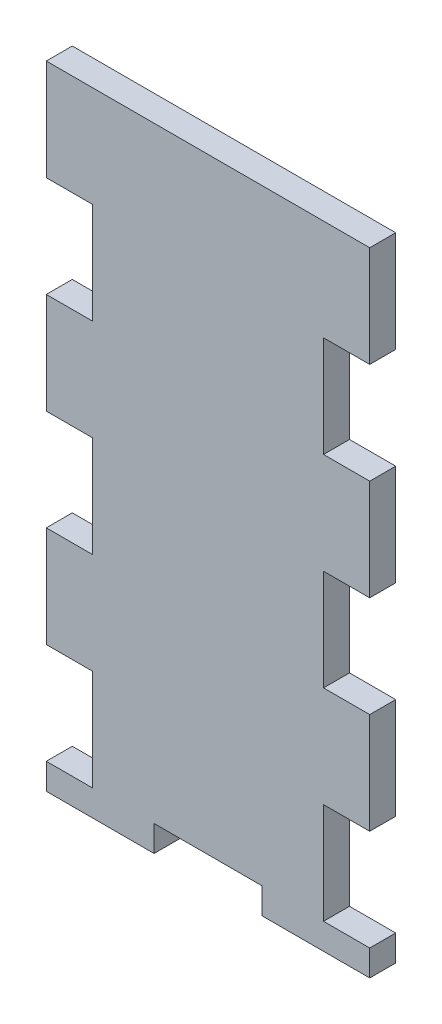
from build123d import *

# Parameters (mm, degrees)
SKETCH1_W           = 20
SKETCH1_H           = 70
SKETCH1_W_2         = 4
SKETCH1_H_2         = 8.75
BOSS_EXTRUDE1_DEPTH = 2.25
SKETCH2_W           = 28
SKETCH2_H           = 2.25
BOSS_EXTRUDE2_DEPTH = 2.25
SKETCH3_W           = 9.333333334
SKETCH3_H           = 2.25
CUT_EXTRUDE1_DEPTH  = 3.25
SKETCH4_W           = 2.25
SKETCH4_H           = 8.75
CUT_EXTRUDE2_DEPTH  = 3.25
SKETCH5_W           = 28
SKETCH5_H           = 17.5
CUT_EXTRUDE3_DEPTH  = 3.25


with BuildPart() as part:
    # Sketch1 → Boss-Extrude1 (new body)
    with BuildSketch(Plane.XY):
        with Locations((10, 35)):
            Rectangle(SKETCH1_W, SKETCH1_H)
        with Locations((-2, 48.125)):
            Rectangle(SKETCH1_W_2, SKETCH1_H_2)
        with Locations((-2, 13.125)):
            Rectangle(SKETCH1_W_2, SKETCH1_H_2)
        with Locations((-2, 65.625)):
            Rectangle(SKETCH1_W_2, SKETCH1_H_2)
        with Locations((22, 65.625)):
            Rectangle(SKETCH1_W_2, SKETCH1_H_2)
        with Locations((22, 48.125)):
            Rectangle(SKETCH1_W_2, SKETCH1_H_2)
        with Locations((22, 13.125)):
            Rectangle(SKETCH1_W_2, SKETCH1_H_2)
        with Locations((22, 30.625)):
            Rectangle(SKETCH1_W_2, SKETCH1_H_2)
        with Locations((-2, 30.625)):
            Rectangle(SKETCH1_W_2, SKETCH1_H_2)
    extrude(amount=BOSS_EXTRUDE1_DEPTH)

    # Sketch2 → Boss-Extrude2 (add)
    with BuildSketch(Plane(origin=(0, 0, 0), x_dir=(-1, 0, 0), z_dir=(0, 0, -1))):
        with Locations((-10, -1.125)):
            Rectangle(SKETCH2_W, SKETCH2_H)
    extrude(amount=-BOSS_EXTRUDE2_DEPTH)

    # Sketch3 → Cut-Extrude1 (cut, through all)
    with BuildSketch(Plane.XY.offset(2.25)):
        with Locations((10, -1.125)):
            Rectangle(SKETCH3_W, SKETCH3_H)
    extrude(amount=-CUT_EXTRUDE1_DEPTH, mode=Mode.SUBTRACT)

    # Sketch4 → Cut-Extrude2 (cut, through all)
    with BuildSketch(Plane.XY.offset(2.25)):
        with Locations((-2.875, 65.625)):
            Rectangle(SKETCH4_W, SKETCH4_H)
        with Locations((22.875, 65.625)):
            Rectangle(SKETCH4_W, SKETCH4_H)
    extrude(amount=-CUT_EXTRUDE2_DEPTH, mode=Mode.SUBTRACT)

    # Sketch5 → Cut-Extrude3 (cut, through all)
    with BuildSketch(Plane.XY.offset(2.25)):
        with Locations((10, 61.25)):
            Rectangle(SKETCH5_W, SKETCH5_H)
    extrude(amount=-CUT_EXTRUDE3_DEPTH, mode=Mode.SUBTRACT)


solid = part.part
